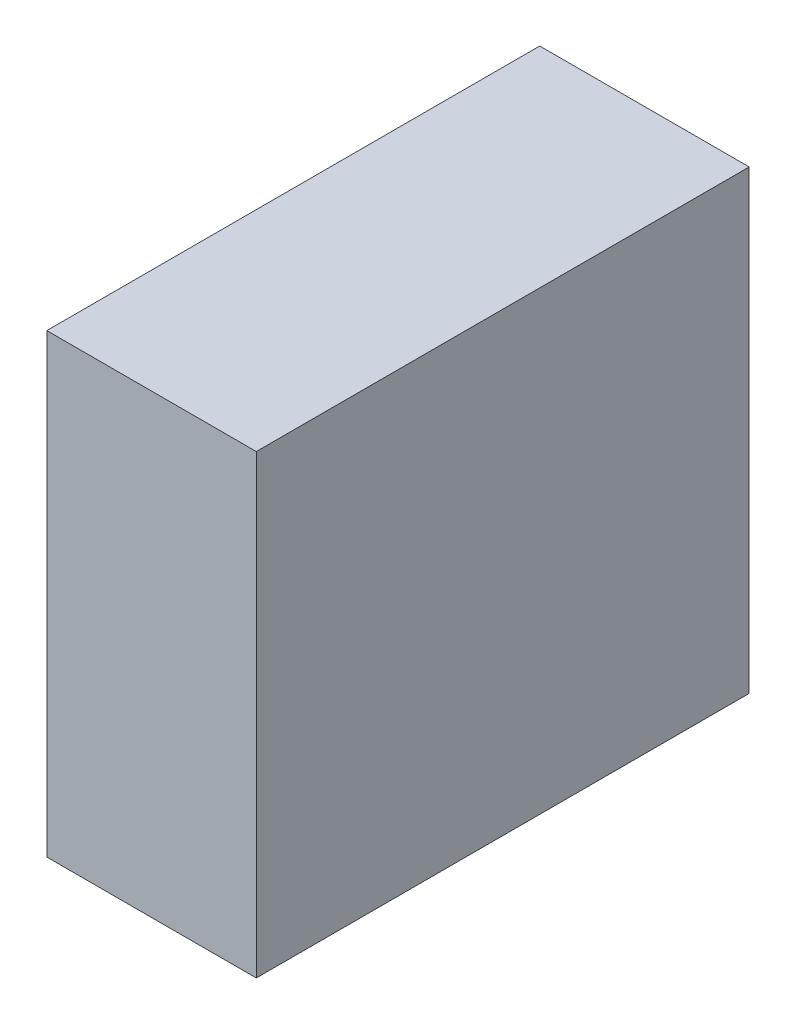
from build123d import *

# Parameters (mm, degrees)
SKETCH1_W      = 170
SKETCH1_H      = 370
EXTRUDE1_DEPTH = 400


with BuildPart() as part:
    # Sketch1 → Extrude1 (new body)
    with BuildSketch(Plane.XY):
        with Locations((85, 185)):
            Rectangle(SKETCH1_W, SKETCH1_H)
    extrude(amount=EXTRUDE1_DEPTH)


solid = part.part
